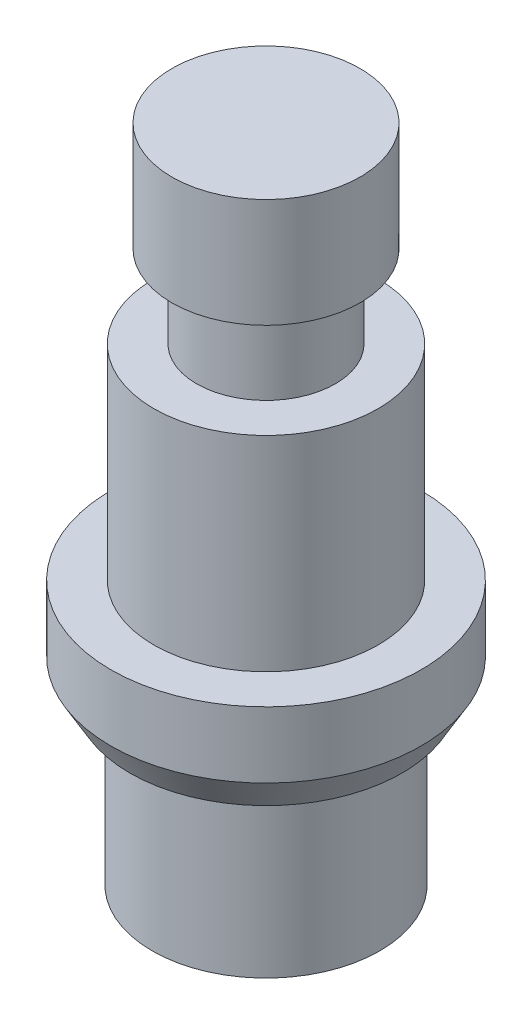
from build123d import *

# Parameters (mm, degrees)
SKETCH1_R           = 4.7
BOSS_EXTRUDE1_DEPTH = 20
SKETCH2_OUTSIDE_W   = 16.202
SKETCH2_OUTSIDE_H   = 16.202
SKETCH2_OUTSIDE_R   = 3.45
CUT_EXTRUDE1_DEPTH  = 5
SKETCH4_OUTSIDE_W   = 16.202
SKETCH4_OUTSIDE_H   = 16.202
SKETCH4_OUTSIDE_R   = 3.4
CUT_EXTRUDE2_DEPTH  = 12
SKETCH5_OUTSIDE_W   = 16.202
SKETCH5_OUTSIDE_H   = 16.202
SKETCH5_OUTSIDE_R   = 2.85
CUT_EXTRUDE3_DEPTH  = 3.3
SKETCH7_OUTSIDE_W   = 16.202
SKETCH7_OUTSIDE_H   = 16.202
SKETCH7_OUTSIDE_R   = 2.1
CUT_EXTRUDE4_DEPTH  = 2.5
CHAMFER1_SIZE       = 1
CHAMFER1_SIZE2      = 0.577350269


with BuildPart() as part:
    # Sketch1 → Boss-Extrude1 (new body)
    with BuildSketch(Plane(origin=(0, 0, 0), x_dir=(1, 0, 0), z_dir=(0, 1, 0))):
        with Locations(Location((0, 0, 0), (0, 0, 270))):  # turned: the seam where the file's is
            Circle(SKETCH1_R)
    extrude(amount=BOSS_EXTRUDE1_DEPTH)

    # Sketch2 outside → Cut-Extrude1 (cut)
    with BuildSketch(Plane.XZ):
        Rectangle(SKETCH2_OUTSIDE_W, SKETCH2_OUTSIDE_H)
        with Locations(Location((0, 0, 0), (0, 0, 270))):  # turned: the seam where the file's is
            Circle(SKETCH2_OUTSIDE_R, mode=Mode.SUBTRACT)
    extrude(amount=-CUT_EXTRUDE1_DEPTH, mode=Mode.SUBTRACT)

    # Sketch4 outside → Cut-Extrude2 (cut)
    with BuildSketch(Plane(origin=(0, 20, 0), x_dir=(1, 0, 0), z_dir=(0, 1, 0))):
        Rectangle(SKETCH4_OUTSIDE_W, SKETCH4_OUTSIDE_H)
        with Locations(Location((0, 0, 0), (0, 0, 270))):  # turned: the seam where the file's is
            Circle(SKETCH4_OUTSIDE_R, mode=Mode.SUBTRACT)
    extrude(amount=-CUT_EXTRUDE2_DEPTH, mode=Mode.SUBTRACT)

    # Sketch5 outside → Cut-Extrude3 (cut)
    with BuildSketch(Plane(origin=(0, 20, 0), x_dir=(1, 0, 0), z_dir=(0, 1, 0))):
        Rectangle(SKETCH5_OUTSIDE_W, SKETCH5_OUTSIDE_H)
        with Locations(Location((0, 0, 0), (0, 0, 270))):  # turned: the seam where the file's is
            Circle(SKETCH5_OUTSIDE_R, mode=Mode.SUBTRACT)
    extrude(amount=-CUT_EXTRUDE3_DEPTH, mode=Mode.SUBTRACT)

    # Sketch7 outside → Cut-Extrude4 (cut)
    with BuildSketch(Plane(origin=(0, 16.7, 0), x_dir=(1, 0, 0), z_dir=(0, 1, 0))):
        Rectangle(SKETCH7_OUTSIDE_W, SKETCH7_OUTSIDE_H)
        with Locations(Location((0, 0, 0), (0, 0, 270))):  # turned: the seam where the file's is
            Circle(SKETCH7_OUTSIDE_R, mode=Mode.SUBTRACT)
    extrude(amount=-CUT_EXTRUDE4_DEPTH, mode=Mode.SUBTRACT)

    # Chamfer1
    chamfer1_edges = [part.edges().sort_by_distance(p)[0] for p in [
        (0, 5, -4.7),
    ]]
    chamfer1_side = [part.faces().sort_by_distance(p)[0] for p in [
        (0, 6.5, -4.7),
    ]]
    chamfer(chamfer1_edges, length=CHAMFER1_SIZE, length2=CHAMFER1_SIZE2, reference=chamfer1_side[0])


solid = part.part
